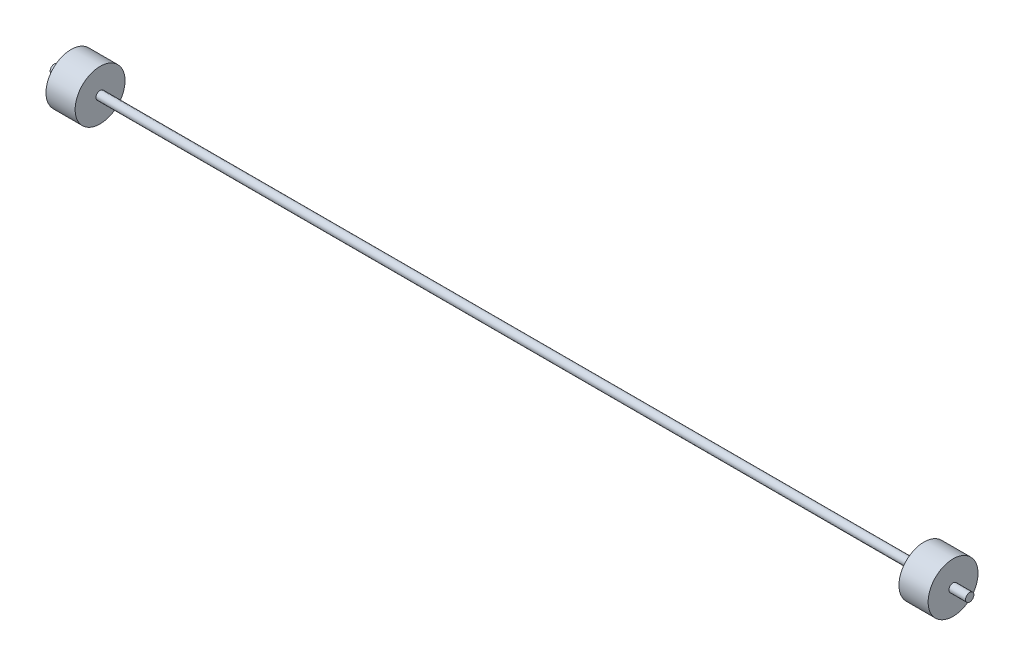
from build123d import *


with BuildPart() as part:
    # Sketch1 → Revolve2 (revolve)
    with BuildSketch(Plane.XY):
        Polygon((-396.661103787, 76.2), (-396.661103787, 12.7), (-447.461103787, 12.7), (-447.461103787, 0), (2346.538896213, 0), (2346.538896213, 12.7), (2295.738896213, 12.7), (2295.738896213, 76.2), (2206.838896213, 76.2), (2206.838896213, 12.7), (-307.761103787, 12.7), (-307.761103787, 76.2), align=None)
    revolve(axis=Axis((-388.888679165, 0, 0), (1, 0, 0)))


solid = part.part
